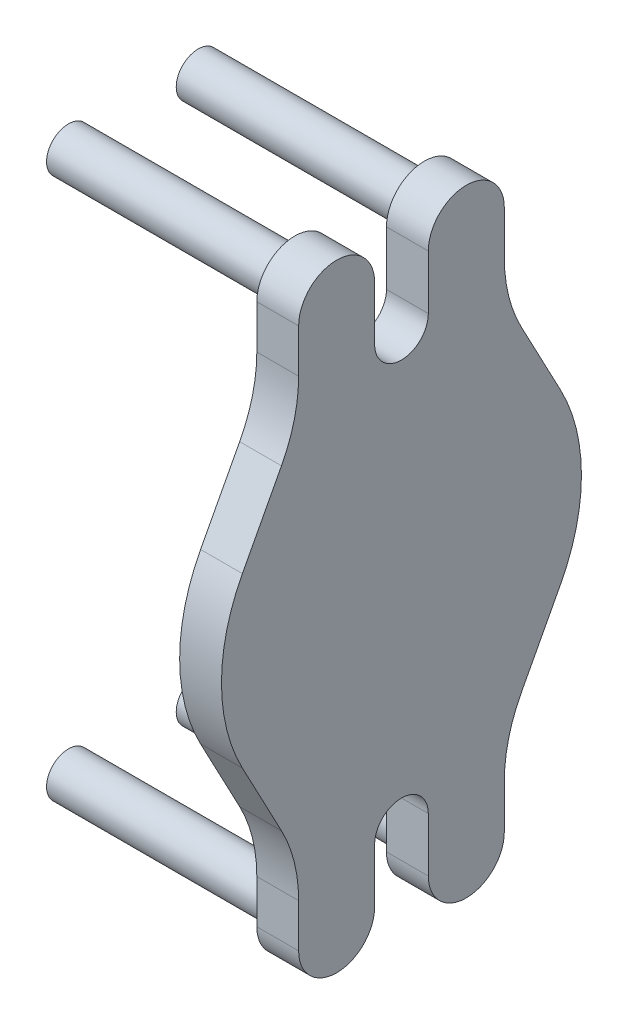
from build123d import *

# Parameters (mm, degrees)
SKETCH1_W           = 17.145
SKETCH1_H           = 18.25
SKETCH2_R           = 3.71475
CUT_EXTRUDE1_DEPTH  = 8.5725
SKETCH3_R           = 18.25
BOSS_EXTRUDE1_DEPTH = 8.5
SKETCH4_R           = 4.45
BOSS_EXTRUDE2_DEPTH = 46
SKETCH5_R           = 18.25
CUT_EXTRUDE2_DEPTH  = 22.15


with BuildPart() as part:
    # Sketch1 → Revolve1 (revolve)
    with BuildSketch(Plane.XY):
        with Locations((16.8275, 9.125)):
            Rectangle(SKETCH1_W, SKETCH1_H)
    revolve(axis=Axis((8.255, 0, 0), (1, 0, 0)))

    # Sketch2 → Cut-Extrude1 (cut)
    with BuildSketch(Plane.ZY.offset(-8.255)):
        Circle(SKETCH2_R)
    extrude(amount=-CUT_EXTRUDE1_DEPTH, mode=Mode.SUBTRACT)


with BuildPart() as body_2:
    # Sketch3 → Boss-Extrude1 (new body)
    with BuildSketch(Plane(origin=(25.4, 0, 0), x_dir=(0, 0, -1), z_dir=(1, 0, 0))):
        with BuildLine():
            Line((-24.382347836, 32.115154563), (-32.324530318, 17.115154563))
            ThreePointArc((-32.324530318, 17.115154563), (-36.576, 0), (-32.324530318, -17.115154563))
            Line((-32.324530318, -17.115154563), (-24.382347836, -32.115154563))
            ThreePointArc((-24.382347836, -32.115154563), (-21.780072988, -38.920854003), (-20.89525, -46.153175037))
            Line((-20.89525, -46.153175037), (-20.89525, -55))
            ThreePointArc((-20.89525, -55), (-13.175, -62.72025), (-5.45475, -55))
            Line((-5.45475, -55), (-5.45475, -44))
            ThreePointArc((-5.45475, -44), (0, -38.54525), (5.45475, -44))
            Line((5.45475, -44), (5.45475, -55))
            ThreePointArc((5.45475, -55), (13.175, -62.72025), (20.89525, -55))
            Line((20.89525, -55), (20.89525, -46.153175037))
            ThreePointArc((20.89525, -46.153175037), (21.780072988, -38.920854003), (24.382347836, -32.115154563))
            Line((24.382347836, -32.115154563), (32.324530318, -17.115154563))
            ThreePointArc((32.324530318, -17.115154563), (36.576, 0), (32.324530318, 17.115154563))
            Line((32.324530318, 17.115154563), (24.382347836, 32.115154563))
            ThreePointArc((24.382347836, 32.115154563), (21.780072988, 38.920854003), (20.89525, 46.153175037))
            Line((20.89525, 46.153175037), (20.89525, 55))
            ThreePointArc((20.89525, 55), (13.175, 62.72025), (5.45475, 55))
            Line((5.45475, 55), (5.45475, 44))
            ThreePointArc((5.45475, 44), (0, 38.54525), (-5.45475, 44))
            Line((-5.45475, 44), (-5.45475, 55))
            ThreePointArc((-5.45475, 55), (-13.175, 62.72025), (-20.89525, 55))
            Line((-20.89525, 55), (-20.89525, 46.153175037))
            ThreePointArc((-20.89525, 46.153175037), (-21.780072988, 38.920854003), (-24.382347836, 32.115154563))
        make_face()
        Circle(SKETCH3_R, mode=Mode.SUBTRACT)
        Circle(SKETCH3_R)
    extrude(amount=BOSS_EXTRUDE1_DEPTH)

    # Sketch4 → Boss-Extrude2 (add)
    with BuildSketch(Plane.ZY.offset(-25.4)):
        with Locations((-13.175, 55)):
            Circle(SKETCH4_R)
        with Locations((13.175, -55)):
            Circle(SKETCH4_R)
        with Locations((13.175, 55)):
            Circle(SKETCH4_R)
        with Locations((-13.175, -55)):
            Circle(SKETCH4_R)
    extrude(amount=BOSS_EXTRUDE2_DEPTH)


with BuildPart() as cut_extrude2_tool:
    # Sketch5 → Cut-Extrude2 (new body)
    with BuildSketch(Plane.ZY.offset(-8.255)):
        Circle(SKETCH5_R)
    extrude(amount=-CUT_EXTRUDE2_DEPTH)


with BuildPart() as part_1:
    add(part.part)

    # Cut-Extrude2: cut by cut_extrude2_tool
    add(cut_extrude2_tool.part, mode=Mode.SUBTRACT)


with BuildPart() as body_2_1:
    add(body_2.part)

    # Cut-Extrude2: cut by cut_extrude2_tool
    add(cut_extrude2_tool.part, mode=Mode.SUBTRACT)


solid = body_2_1.part
